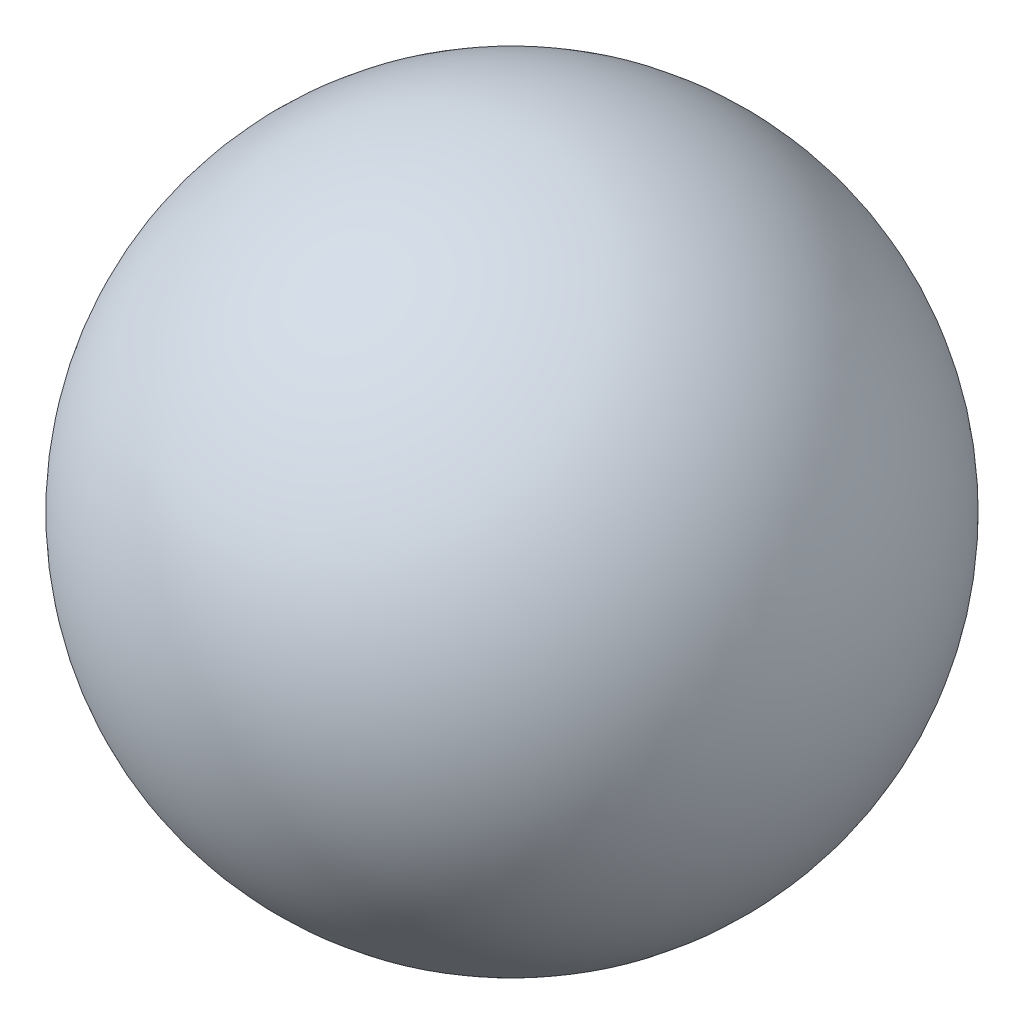
from build123d import *


with BuildPart() as part:
    # Sketch2 → Revolve1 (revolve)
    with BuildSketch(Plane.XY):
        with BuildLine():
            Line((0, 3.96875), (0, -3.96875))
            ThreePointArc((0, -3.96875), (-3.96875, 0), (0, 3.96875))
        make_face()
    revolve(axis=Axis((0, -7.156698923, 0), (0, 1, 0)))


solid = part.part
